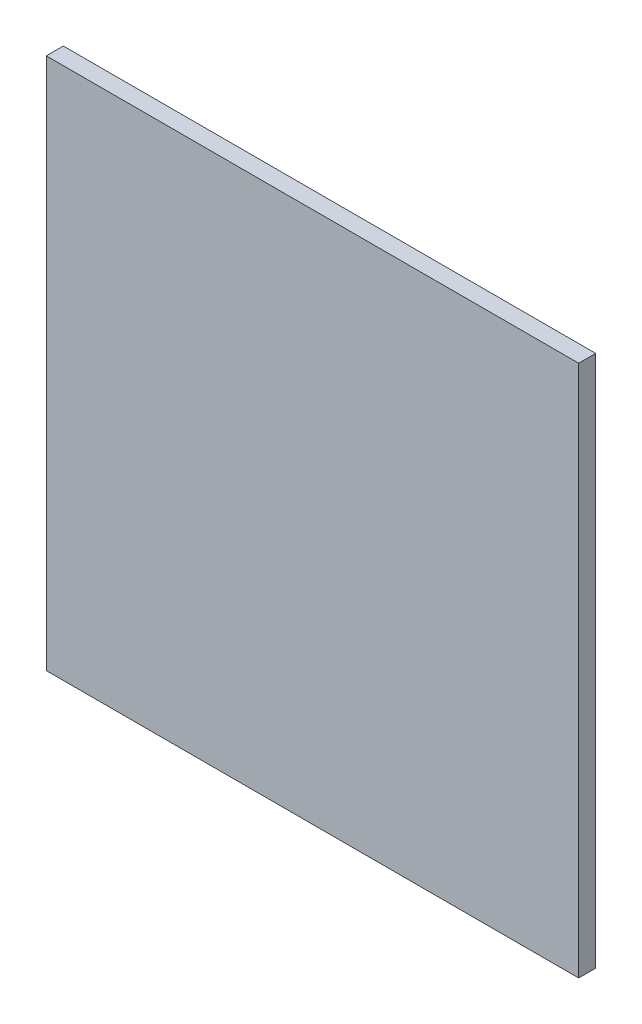
from build123d import *

# Parameters (mm, degrees)
SKETCH1_W           = 100
SKETCH1_H           = 100
BOSS_EXTRUDE1_DEPTH = 3.2


with BuildPart() as part:
    # Sketch1 → Boss-Extrude1 (new body)
    with BuildSketch(Plane.XY):
        Rectangle(SKETCH1_W, SKETCH1_H)
    extrude(amount=BOSS_EXTRUDE1_DEPTH)


solid = part.part
